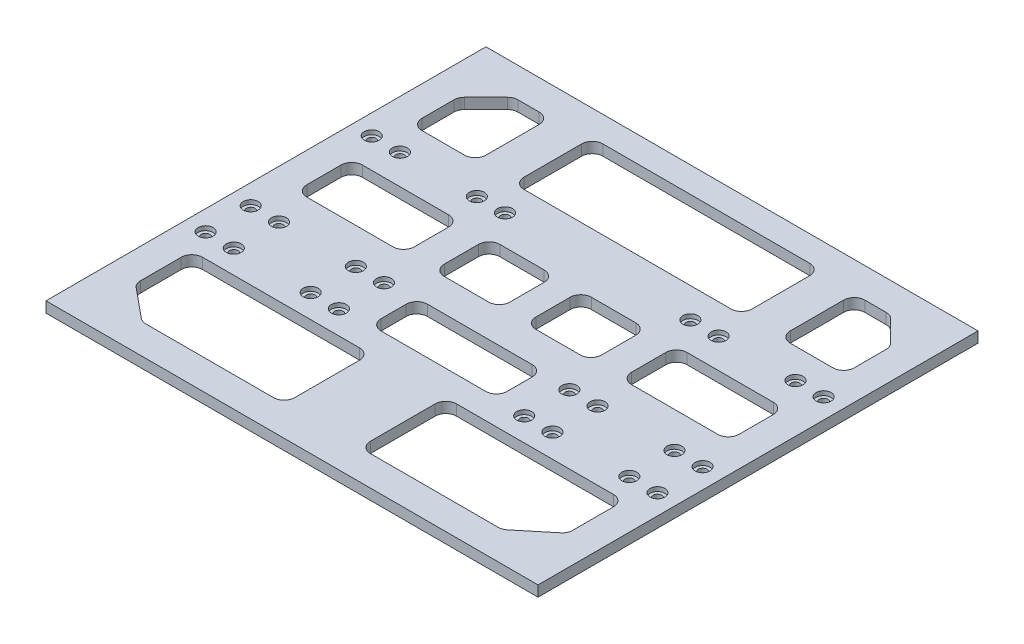
from build123d import *

# Parameters (mm, degrees)
SKETCH1_W           = 115
SKETCH1_H           = 103
BOSS_EXTRUDE1_DEPTH = 2.5
SKETCH2_R           = 1
CUT_EXTRUDE1_DEPTH  = 10
SKETCH3_W           = 103
SKETCH3_H           = 2.5
BOSS_EXTRUDE2_DEPTH = 0.1
SKETCH4_W           = 103
SKETCH4_H           = 2.5
BOSS_EXTRUDE3_DEPTH = 0.1
CUT_EXTRUDE3_DEPTH  = 10
SKETCH7_R           = 1.75
CUT_EXTRUDE4_DEPTH  = 1


with BuildPart() as part:
    # Sketch1 → Boss-Extrude1 (new body)
    with BuildSketch(Plane(origin=(0, 0, 0), x_dir=(1, 0, 0), z_dir=(0, 1, 0))):
        Rectangle(SKETCH1_W, SKETCH1_H)
    extrude(amount=BOSS_EXTRUDE1_DEPTH)

    # Sketch2 → Cut-Extrude1 (cut)
    with BuildSketch(Plane.XZ):
        with Locations((-52.9, -20.06)):
            Circle(SKETCH2_R)
        with Locations((-52.9, 8.27)):
            Circle(SKETCH2_R)
        with Locations((-52.9, 18.84)):
            Circle(SKETCH2_R)
        with Locations((52.9, -20.06)):
            Circle(SKETCH2_R)
        with Locations((52.9, 8.27)):
            Circle(SKETCH2_R)
        with Locations((52.9, 18.84)):
            Circle(SKETCH2_R)
        with Locations((-46.3, 18.84)):
            Circle(SKETCH2_R)
        with Locations((-46.3, -20.06)):
            Circle(SKETCH2_R)
        with Locations((-46.3, 8.27)):
            Circle(SKETCH2_R)
        with Locations((46.3, -20.06)):
            Circle(SKETCH2_R)
        with Locations((46.3, 8.27)):
            Circle(SKETCH2_R)
        with Locations((46.3, 18.84)):
            Circle(SKETCH2_R)
        with Locations((-28.3, 18.84)):
            Circle(SKETCH2_R)
        with Locations((-21.7, 18.84)):
            Circle(SKETCH2_R)
        with Locations((-21.7, 8.27)):
            Circle(SKETCH2_R)
        with Locations((-28.3, 8.27)):
            Circle(SKETCH2_R)
        with Locations((-21.7, -20.06)):
            Circle(SKETCH2_R)
        with Locations((-28.3, -20.06)):
            Circle(SKETCH2_R)
        with Locations((21.7, 18.84)):
            Circle(SKETCH2_R)
        with Locations((28.3, 18.84)):
            Circle(SKETCH2_R)
        with Locations((28.3, 8.27)):
            Circle(SKETCH2_R)
        with Locations((21.7, 8.27)):
            Circle(SKETCH2_R)
        with Locations((28.3, -20.06)):
            Circle(SKETCH2_R)
        with Locations((21.7, -20.06)):
            Circle(SKETCH2_R)
    extrude(amount=-CUT_EXTRUDE1_DEPTH, mode=Mode.SUBTRACT)

    # Sketch3 → Boss-Extrude2 (add)
    with BuildSketch(Plane.ZY.offset(57.5)):
        with Locations((0, 1.25)):
            Rectangle(SKETCH3_W, SKETCH3_H)
    extrude(amount=BOSS_EXTRUDE2_DEPTH)

    # Sketch4 → Boss-Extrude3 (add)
    with BuildSketch(Plane(origin=(57.5, 0, 0), x_dir=(0, 0, -1), z_dir=(1, 0, 0))):
        with Locations((0, 1.25)):
            Rectangle(SKETCH4_W, SKETCH4_H)
    extrude(amount=BOSS_EXTRUDE3_DEPTH)

    # Sketch6 → Cut-Extrude3 (cut)
    with BuildSketch(Plane(origin=(0, 2.5, 0), x_dir=(1, 0, 0), z_dir=(0, 1, 0))):
        with BuildLine():
            Line((-44.876180251, 43.767766953), (-49.867766953, 38.776180251))
            ThreePointArc((-49.867766953, 38.776180251), (-50.409698831, 37.965121879), (-50.6, 37.008413298))
            Line((-50.6, 37.008413298), (-50.6, 29.525557041))
            ThreePointArc((-50.6, 29.525557041), (-49.867766953, 27.757790088), (-48.1, 27.025557041))
            Line((-48.1, 27.025557041), (-38.125738345, 27.025557041))
            ThreePointArc((-38.125738345, 27.025557041), (-36.357971392, 27.757790088), (-35.625738345, 29.525557041))
            Line((-35.625738345, 29.525557041), (-35.625738345, 42))
            ThreePointArc((-35.625738345, 42), (-36.357971392, 43.767766953), (-38.125738345, 44.5))
            Line((-38.125738345, 44.5), (-43.108413298, 44.5))
            ThreePointArc((-43.108413298, 44.5), (-44.065121879, 44.309698831), (-44.876180251, 43.767766953))
        make_face()
        with BuildLine():
            Line((-24.211357367, 45.5), (24.211357367, 45.5))
            ThreePointArc((24.211357367, 45.5), (25.97912432, 44.767766953), (26.711357367, 43))
            Line((26.711357367, 43), (26.711357367, 29.525557041))
            ThreePointArc((26.711357367, 29.525557041), (25.97912432, 27.757790088), (24.211357367, 27.025557041))
            Line((24.211357367, 27.025557041), (-24.211357367, 27.025557041))
            ThreePointArc((-24.211357367, 27.025557041), (-25.97912432, 27.757790088), (-26.711357367, 29.525557041))
            Line((-26.711357367, 29.525557041), (-26.711357367, 43))
            ThreePointArc((-26.711357367, 43), (-25.97912432, 44.767766953), (-24.211357367, 45.5))
        make_face()
        with BuildLine():
            Line((-49.688762468, -38.300141018), (-42.84856017, -43.930241908))
            ThreePointArc((-42.84856017, -43.930241908), (-42.103715717, -44.353253574), (-41.259797703, -44.5))
            Line((-41.259797703, -44.5), (-11.348843163, -44.5))
            ThreePointArc((-11.348843163, -44.5), (-9.58107621, -43.767766953), (-8.848843163, -42))
            Line((-8.848843163, -42), (-8.848843163, -26.836258094))
            ThreePointArc((-8.848843163, -26.836258094), (-9.58107621, -25.068491141), (-11.348843163, -24.336258094))
            Line((-11.348843163, -24.336258094), (-48.1, -24.336258094))
            ThreePointArc((-48.1, -24.336258094), (-49.867766953, -25.068491141), (-50.6, -26.836258094))
            Line((-50.6, -26.836258094), (-50.6, -36.369899111))
            ThreePointArc((-50.6, -36.369899111), (-50.360741711, -37.43716052), (-49.688762468, -38.300141018))
        make_face()
        with BuildLine():
            Line((-48.1, 0.056382832), (-27.927103688, 0.056382832))
            ThreePointArc((-27.927103688, 0.056382832), (-26.159336735, 0.788615879), (-25.427103688, 2.556382832))
            Line((-25.427103688, 2.556382832), (-25.427103688, 10.569015944))
            ThreePointArc((-25.427103688, 10.569015944), (-26.159336735, 12.336782897), (-27.927103688, 13.069015944))
            Line((-27.927103688, 13.069015944), (-48.1, 13.069015944))
            ThreePointArc((-48.1, 13.069015944), (-49.867766953, 12.336782897), (-50.6, 10.569015944))
            Line((-50.6, 10.569015944), (-50.6, 2.556382832))
            ThreePointArc((-50.6, 2.556382832), (-49.867766953, 0.788615879), (-48.1, 0.056382832))
        make_face()
        with BuildLine():
            Line((-15.91791754, 0.056382832), (-5.533746838, 0.056382832))
            ThreePointArc((-5.533746838, 0.056382832), (-3.765979885, 0.788615879), (-3.033746838, 2.556382832))
            Line((-3.033746838, 2.556382832), (-3.033746838, 10.569015944))
            ThreePointArc((-3.033746838, 10.569015944), (-3.765979885, 12.336782897), (-5.533746838, 13.069015944))
            Line((-5.533746838, 13.069015944), (-15.91791754, 13.069015944))
            ThreePointArc((-15.91791754, 13.069015944), (-17.685684493, 12.336782897), (-18.41791754, 10.569015944))
            Line((-18.41791754, 10.569015944), (-18.41791754, 2.556382832))
            ThreePointArc((-18.41791754, 2.556382832), (-17.685684493, 0.788615879), (-15.91791754, 0.056382832))
        make_face()
        with BuildLine():
            Line((41.259797703, -44.5), (11.348843163, -44.5))
            ThreePointArc((11.348843163, -44.5), (9.58107621, -43.767766953), (8.848843163, -42))
            Line((8.848843163, -42), (8.848843163, -26.836258094))
            ThreePointArc((8.848843163, -26.836258094), (9.58107621, -25.068491141), (11.348843163, -24.336258094))
            Line((11.348843163, -24.336258094), (48.1, -24.336258094))
            ThreePointArc((48.1, -24.336258094), (49.867766953, -25.068491141), (50.6, -26.836258094))
            Line((50.6, -26.836258094), (50.6, -36.369899111))
            ThreePointArc((50.6, -36.369899111), (50.360741711, -37.43716052), (49.688762468, -38.300141018))
            Line((49.688762468, -38.300141018), (42.84856017, -43.930241908))
            ThreePointArc((42.84856017, -43.930241908), (42.103715717, -44.353253574), (41.259797703, -44.5))
        make_face()
        with BuildLine():
            Line((-12.250112184, -18.396518995), (12.250112184, -18.396518995))
            ThreePointArc((12.250112184, -18.396518995), (14.017879137, -17.664285948), (14.750112184, -15.896518995))
            Line((14.750112184, -15.896518995), (14.750112184, -10.023618282))
            ThreePointArc((14.750112184, -10.023618282), (14.017879137, -8.255851329), (12.250112184, -7.523618282))
            Line((12.250112184, -7.523618282), (-12.250112184, -7.523618282))
            ThreePointArc((-12.250112184, -7.523618282), (-14.017879137, -8.255851329), (-14.750112184, -10.023618282))
            Line((-14.750112184, -10.023618282), (-14.750112184, -15.896518995))
            ThreePointArc((-14.750112184, -15.896518995), (-14.017879137, -17.664285948), (-12.250112184, -18.396518995))
        make_face()
        with BuildLine():
            Line((3.033746838, 2.556382832), (3.033746838, 10.569015944))
            ThreePointArc((3.033746838, 10.569015944), (3.765979885, 12.336782897), (5.533746838, 13.069015944))
            Line((5.533746838, 13.069015944), (15.91791754, 13.069015944))
            ThreePointArc((15.91791754, 13.069015944), (17.685684493, 12.336782897), (18.41791754, 10.569015944))
            Line((18.41791754, 10.569015944), (18.41791754, 2.556382832))
            ThreePointArc((18.41791754, 2.556382832), (17.685684493, 0.788615879), (15.91791754, 0.056382832))
            Line((15.91791754, 0.056382832), (5.533746838, 0.056382832))
            ThreePointArc((5.533746838, 0.056382832), (3.765979885, 0.788615879), (3.033746838, 2.556382832))
        make_face()
        with BuildLine():
            Line((48.1, 0.056382832), (27.927103688, 0.056382832))
            ThreePointArc((27.927103688, 0.056382832), (26.159336735, 0.788615879), (25.427103688, 2.556382832))
            Line((25.427103688, 2.556382832), (25.427103688, 10.569015944))
            ThreePointArc((25.427103688, 10.569015944), (26.159336735, 12.336782897), (27.927103688, 13.069015944))
            Line((27.927103688, 13.069015944), (48.1, 13.069015944))
            ThreePointArc((48.1, 13.069015944), (49.867766953, 12.336782897), (50.6, 10.569015944))
            Line((50.6, 10.569015944), (50.6, 2.556382832))
            ThreePointArc((50.6, 2.556382832), (49.867766953, 0.788615879), (48.1, 0.056382832))
        make_face()
        with BuildLine():
            Line((48.1, 27.025557041), (38.125738345, 27.025557041))
            ThreePointArc((38.125738345, 27.025557041), (36.357971392, 27.757790088), (35.625738345, 29.525557041))
            Line((35.625738345, 29.525557041), (35.625738345, 42))
            ThreePointArc((35.625738345, 42), (36.357971392, 43.767766953), (38.125738345, 44.5))
            Line((38.125738345, 44.5), (43.108413298, 44.5))
            ThreePointArc((43.108413298, 44.5), (44.065121879, 44.309698831), (44.876180251, 43.767766953))
            Line((44.876180251, 43.767766953), (49.867766953, 38.776180251))
            ThreePointArc((49.867766953, 38.776180251), (50.409698831, 37.965121879), (50.6, 37.008413298))
            Line((50.6, 37.008413298), (50.6, 29.525557041))
            ThreePointArc((50.6, 29.525557041), (49.867766953, 27.757790088), (48.1, 27.025557041))
        make_face()
    extrude(amount=-CUT_EXTRUDE3_DEPTH, mode=Mode.SUBTRACT)

    # Sketch7 → Cut-Extrude4 (cut)
    with BuildSketch(Plane(origin=(0, 2.5, 0), x_dir=(1, 0, 0), z_dir=(0, 1, 0))):
        with Locations((-52.9, 20.06)):
            Circle(SKETCH7_R)
        with Locations((-46.3, 20.06)):
            Circle(SKETCH7_R)
        with Locations((-52.9, -8.27)):
            Circle(SKETCH7_R)
        with Locations((-46.3, -8.27)):
            Circle(SKETCH7_R)
        with Locations((-52.9, -18.84)):
            Circle(SKETCH7_R)
        with Locations((-46.3, -18.84)):
            Circle(SKETCH7_R)
        with Locations((-28.3, -18.84)):
            Circle(SKETCH7_R)
        with Locations((-21.7, -18.84)):
            Circle(SKETCH7_R)
        with Locations((-28.3, -8.27)):
            Circle(SKETCH7_R)
        with Locations((-21.7, -8.27)):
            Circle(SKETCH7_R)
        with Locations((-21.7, 20.06)):
            Circle(SKETCH7_R)
        with Locations((-28.3, 20.06)):
            Circle(SKETCH7_R)
        with Locations((21.7, -18.84)):
            Circle(SKETCH7_R)
        with Locations((28.3, -18.84)):
            Circle(SKETCH7_R)
        with Locations((46.3, -18.84)):
            Circle(SKETCH7_R)
        with Locations((52.9, -18.84)):
            Circle(SKETCH7_R)
        with Locations((21.7, -8.27)):
            Circle(SKETCH7_R)
        with Locations((28.3, -8.27)):
            Circle(SKETCH7_R)
        with Locations((46.3, -8.27)):
            Circle(SKETCH7_R)
        with Locations((52.9, -8.27)):
            Circle(SKETCH7_R)
        with Locations((21.7, 20.06)):
            Circle(SKETCH7_R)
        with Locations((28.3, 20.06)):
            Circle(SKETCH7_R)
        with Locations((46.3, 20.06)):
            Circle(SKETCH7_R)
        with Locations((52.9, 20.06)):
            Circle(SKETCH7_R)
    extrude(amount=-CUT_EXTRUDE4_DEPTH, mode=Mode.SUBTRACT)


solid = part.part
